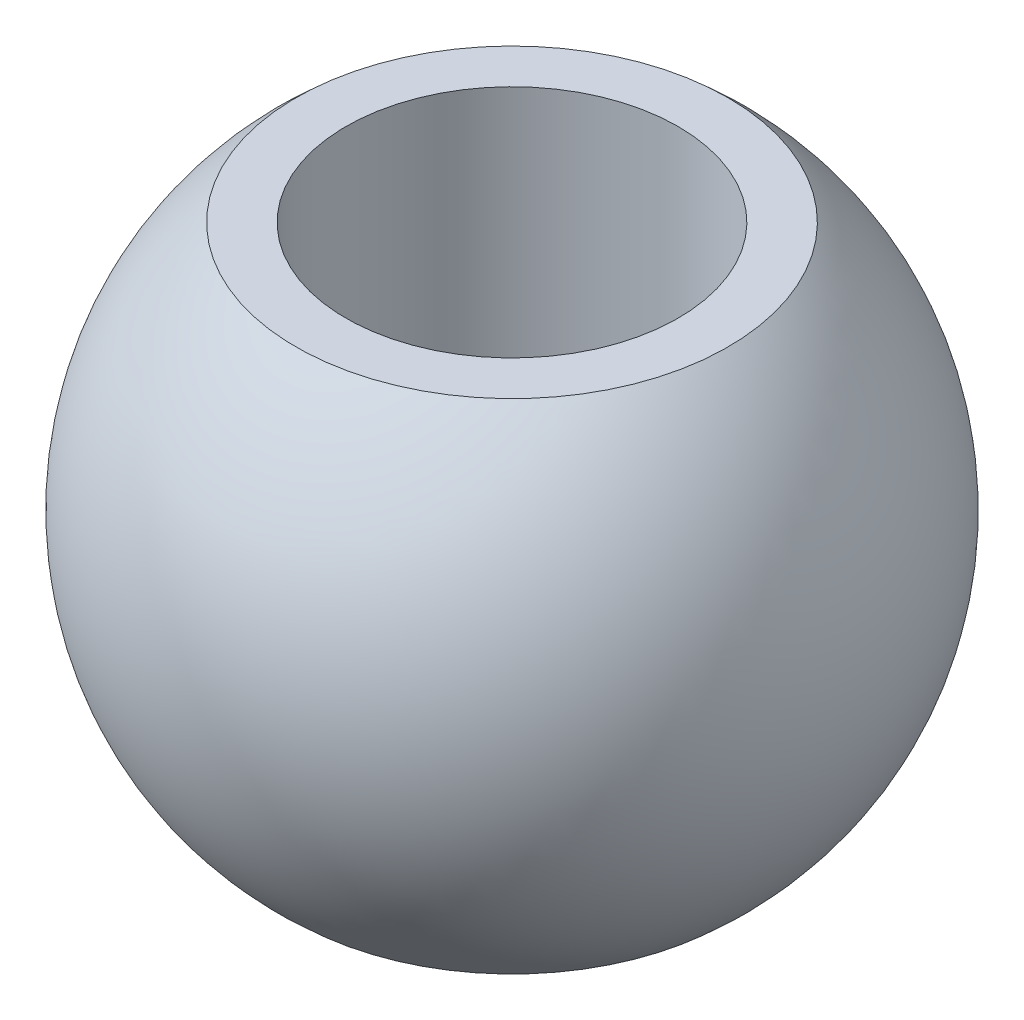
from build123d import *


with BuildPart() as part:
    # Szkic1 → Obrót1 (revolve)
    with BuildSketch(Plane.XY):
        with BuildLine():
            Line((4, -6), (4, 6))
            Line((4, 6), (5.200346142, 6))
            ThreePointArc((5.200346142, 6), (7.94, 0), (5.200346142, -6))
            Line((5.200346142, -6), (4, -6))
        make_face()
    revolve(axis=Axis((0, -11.1, 0), (0, 1, 0)))


solid = part.part
